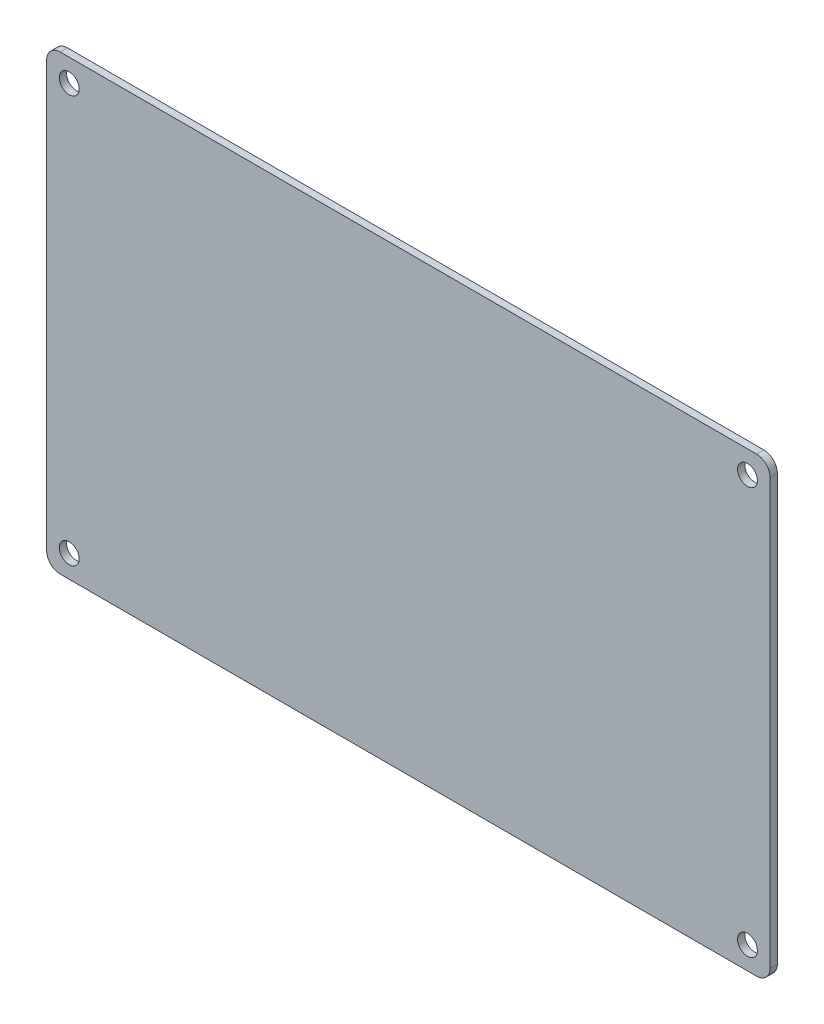
from build123d import *

# Parameters (mm, degrees)
SKETCH_1_W             = 160
SKETCH_1_H             = 100
EXTRUDE_1_DEPTH        = 1.6
FILLET_1_R             = 3
HOLE_WIZARD_M3_1_D     = 4.4
HOLE_WIZARD_M3_1_DEPTH = 6


with BuildPart() as part:
    # ｽｹｯﾁ1 → ﾎﾞｽ - 押し出し1 (new body)
    with BuildSketch(Plane.XY):
        Rectangle(SKETCH_1_W, SKETCH_1_H)
    extrude(amount=EXTRUDE_1_DEPTH)

    # ﾌｨﾚｯﾄ1
    fillet_1_edges = [part.edges().sort_by_distance(p)[0] for p in [
        (-80, 50, 0.8),
        (80, 50, 0.8),
        (80, -50, 0.8),
        (-80, -50, 0.8),
    ]]
    fillet(fillet_1_edges, radius=FILLET_1_R)

    # M3 すきま穴1
    with Locations(Plane.XY.offset(1.6)):
        with Locations((-75, -45), (-75, 45), (75, 45), (75, -45)):
            Hole(HOLE_WIZARD_M3_1_D / 2, depth=HOLE_WIZARD_M3_1_DEPTH)


solid = part.part
